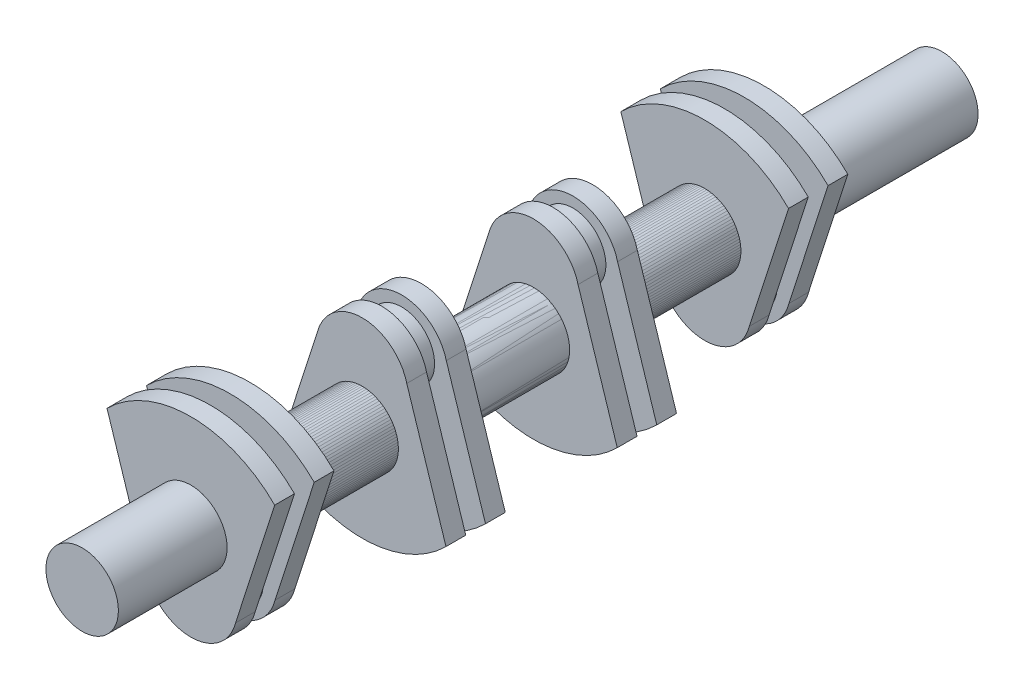
from build123d import *

# Parameters (mm, degrees)
BOSS_EXTRUDE1_DEPTH   = 15
SKETCH3_R             = 25
BOSS_EXTRUDE2_DEPTH   = 30
SKETCH4_R             = 27.5
BOSS_EXTRUDE3_DEPTH   = 85
BODY_MOVE_COPY3_ANGLE = 180
BOSS_EXTRUDE5_START   = 302.5
SKETCH6_R             = 27.5
BOSS_EXTRUDE5_DEPTH   = 50
SKETCH5_R             = 27.5
CUT_EXTRUDE4_DEPTH    = 2.5


with BuildPart() as part:
    # Sketch1 → Boss-Extrude1 (new body)
    with BuildSketch(Plane.XY):
        with BuildLine():
            Line((-63.639610307, 58.639610307), (-33.888985145, -33.748524782))
            ThreePointArc((-33.888985145, -33.748524782), (0, -60), (33.888985145, -33.748524782))
            Line((33.888985145, -33.748524782), (63.639610307, 58.639610307))
            ThreePointArc((63.639610307, 58.639610307), (0, 85), (-63.639610307, 58.639610307))
        make_face()
    extrude(amount=BOSS_EXTRUDE1_DEPTH)

    # Sketch3 → Boss-Extrude2 (add)
    with BuildSketch(Plane.XY.offset(15)):
        with Locations((0, -27.10409222)):
            Circle(SKETCH3_R)
    extrude(amount=-BOSS_EXTRUDE2_DEPTH)

    # Sketch4 → Boss-Extrude3 (add)
    with BuildSketch(Plane.XY.offset(15)):
        with Locations((0, 12.5)):
            Circle(SKETCH4_R)
    extrude(amount=BOSS_EXTRUDE3_DEPTH)

    # Mirror5: part across plane


with BuildPart() as part_1:
    add(part.part)
    add(part.part.mirror(Plane(origin=(0, 0, -7.5), x_dir=(1, 0, 0), z_dir=(0, 0, -1))))


with BuildPart() as body_2:
    # Mirror6: mirrored copy
    add(part_1.part.mirror(Plane(origin=(0, 0, -72.5), x_dir=(1, 0, 0), z_dir=(0, 0, -1))))


with BuildPart() as body_2_1:
    # Body-Move/Copy3: moved
    add(body_2.part.rotate(Axis((0, 12.5, 0), (0, 0, 1)), BODY_MOVE_COPY3_ANGLE))


with BuildPart() as body_3:
    # Mirror7: mirrored copy
    add(body_2_1.part.mirror(Plane(origin=(0, 0, -202.5), x_dir=(1, 0, 0), z_dir=(0, 0, -1))))


with BuildPart() as body_4:
    # Mirror9: mirrored copy
    add(part_1.part.mirror(Plane(origin=(0, 0, -202.5), x_dir=(1, 0, 0), z_dir=(0, 0, -1))))

    # Sketch6 → Boss-Extrude5 (add)
    with BuildSketch(Plane(origin=(0, 0, -202.5), x_dir=(-1, 0, 0), z_dir=(0, 0, -1)).offset(BOSS_EXTRUDE5_START)):
        with Locations((0, 12.5)):
            Circle(SKETCH6_R)
    extrude(amount=BOSS_EXTRUDE5_DEPTH)


with BuildPart() as part_2:
    add(part_1.part)

    # Sketch5 → Cut-Extrude4 (cut)
    with BuildSketch(Plane.XY.offset(100)):
        with Locations((0, 12.5)):
            Circle(SKETCH5_R)
    extrude(amount=-CUT_EXTRUDE4_DEPTH, mode=Mode.SUBTRACT)


solid = Compound([body_2_1.part, body_3.part, body_4.part, part_2.part])
